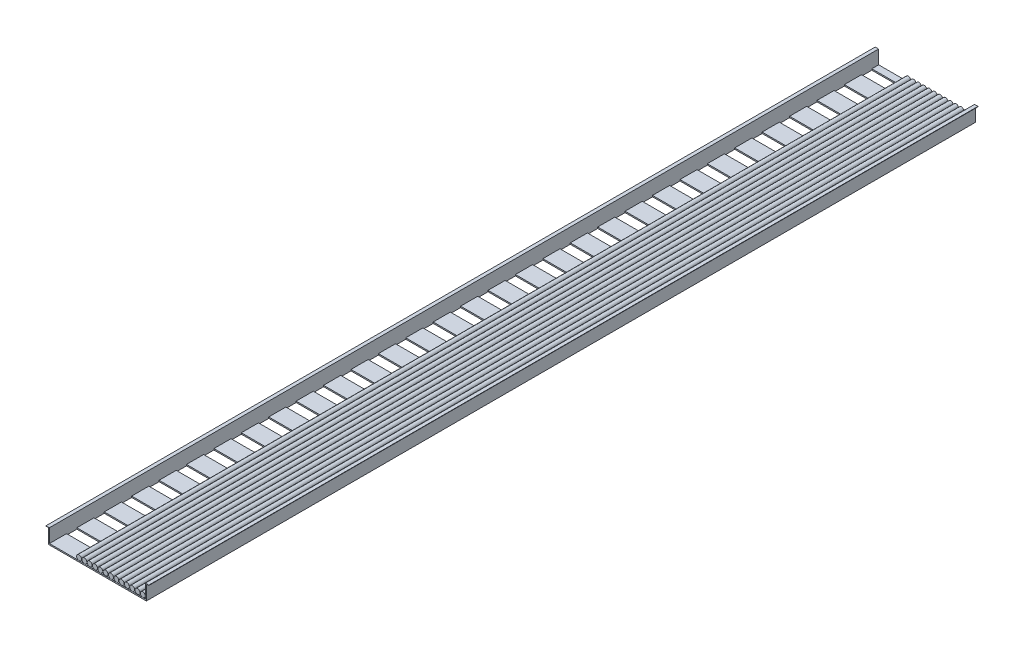
from build123d import *

# Parameters (mm, degrees)
CROQUIS1_W              = 600
CROQUIS1_H              = 120
SALIENTE_EXTRUIR1_DEPTH = 4840
CROQUIS2_W              = 560
CROQUIS2_H              = 80
CORTAR_EXTRUIR1_DEPTH   = 4840
CORTAR_EXTRUIR2_DEPTH   = 4840
CROQUIS4_W              = 560
CROQUIS4_H              = 60
CORTAR_EXTRUIR3_DEPTH   = 4000
MATRIZL1_COUNT          = 30
MATRIZL1_PITCH          = 160
CROQUIS5_R              = 14.5
SALIENTE_EXTRUIR2_DEPTH = 4840
MATRIZL2_COUNT          = 13
MATRIZL2_PITCH          = 31


with BuildPart() as part:
    # Croquis1 → Saliente-Extruir1 (new body)
    with BuildSketch(Plane.XY):
        Rectangle(CROQUIS1_W, CROQUIS1_H)
    extrude(amount=SALIENTE_EXTRUIR1_DEPTH)

    # Croquis2 → Cortar-Extruir1 (cut)
    with BuildSketch(Plane.XY.offset(4840)):
        with Locations((0, 20)):
            Rectangle(CROQUIS2_W, CROQUIS2_H)
    extrude(amount=-CORTAR_EXTRUIR1_DEPTH, mode=Mode.SUBTRACT)

    # Croquis3 → Cortar-Extruir2 (cut)
    with BuildSketch(Plane.XY.offset(4840)):
        Polygon((-286, 58), (-300, 58), (-300, -60), (300, -60), (300, 58), (286, 58), (286, -27.423685892), (-286, -27.423685892), align=None)
    extrude(amount=-CORTAR_EXTRUIR2_DEPTH, mode=Mode.SUBTRACT)

    # Croquis4 → Cortar-Extruir3 (cut)
    with BuildSketch(Plane(origin=(0, -20, 0), x_dir=(1, 0, 0), z_dir=(0, 1, 0))):
        with Locations((0, -4710)):
            Rectangle(CROQUIS4_W, CROQUIS4_H)
    cortar_extruir3 = extrude(amount=-CORTAR_EXTRUIR3_DEPTH, mode=Mode.SUBTRACT)

    # MatrizL1: Cortar-Extruir3 ×30
    with Locations(*[(0, 0, -i * MATRIZL1_PITCH) for i in range(1, MATRIZL1_COUNT)]):
        add(cortar_extruir3, mode=Mode.SUBTRACT)


with BuildPart() as body_2:
    # Croquis5 → Saliente-Extruir2 (new body)
    with BuildSketch(Plane(origin=(0, 0, 0), x_dir=(-1, 0, 0), z_dir=(0, 0, -1))):
        with Locations((-265, -5)):
            Circle(CROQUIS5_R)
    saliente_extruir2 = extrude(amount=-SALIENTE_EXTRUIR2_DEPTH)


with BuildPart() as matrizl2_1:
    # MatrizL2: Saliente-Extruir2 ×13
    with Locations(*[(-i * MATRIZL2_PITCH, 0, 0) for i in range(1, MATRIZL2_COUNT)]):
        add(saliente_extruir2)


solid = Compound([part.part, body_2.part, matrizl2_1.part])
